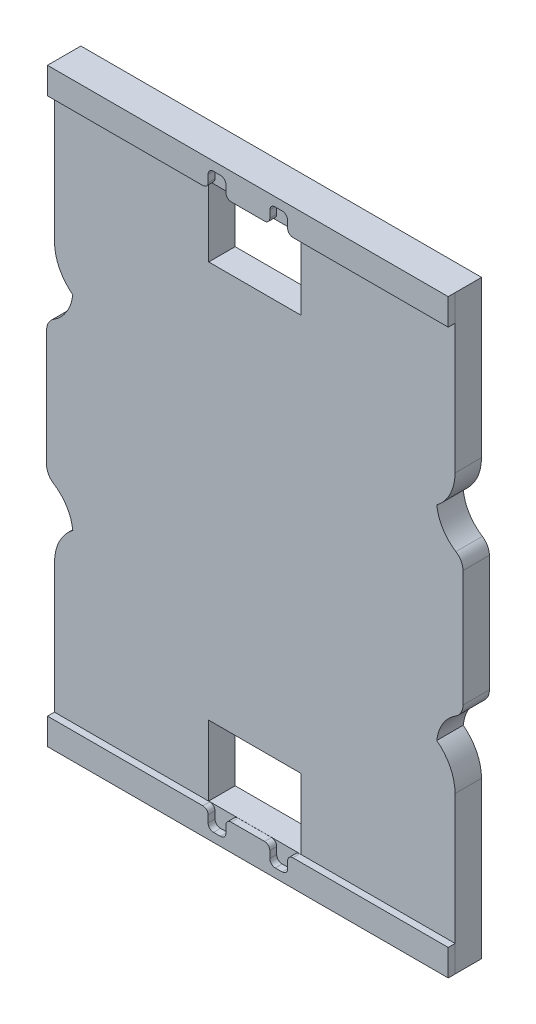
from build123d import *

# Parameters (mm, degrees)
BOSS_EXTRUDE1_DEPTH   = 1.57
BOSS_EXTRUDE1_2_DEPTH = 1.57
SKETCH2_W             = 20.9
SKETCH2_H             = 15.9
SKETCH2_W_2           = 94.45
SKETCH2_H_2           = 0.025
SKETCH2_H_3           = 6.025
BOSS_EXTRUDE3_DEPTH   = 6


with BuildPart() as part:
    # Sketch1 → Boss-Extrude1 (new body)
    with BuildSketch(Plane.XY.offset(7.67)):
        with BuildLine():
            Line((-10.2, 60.925), (-45.45, 60.925))
            Line((-45.45, 60.925), (-45.45, 66.925))
            Line((-45.45, 66.925), (45.45, 66.925))
            Line((45.45, 66.925), (45.45, 60.925))
            Line((45.45, 60.925), (10.2, 60.925))
            ThreePointArc((10.2, 60.925), (9.369149532, 61.269149532), (9.025, 62.1))
            Line((9.025, 62.1), (9.025, 63.7))
            ThreePointArc((9.025, 63.7), (8.666205807, 64.566205807), (7.8, 64.925))
            Line((7.8, 64.925), (6.2, 64.925))
            ThreePointArc((6.2, 64.925), (5.333794193, 64.566205807), (4.975, 63.7))
            Line((4.975, 63.7), (4.975, 62.1))
            ThreePointArc((4.975, 62.1), (4.630850468, 61.269149532), (3.8, 60.925))
            Line((3.8, 60.925), (-3.8, 60.925))
            ThreePointArc((-3.8, 60.925), (-4.630850468, 61.269149532), (-4.975, 62.1))
            Line((-4.975, 62.1), (-4.975, 63.7))
            ThreePointArc((-4.975, 63.7), (-5.333794193, 64.566205807), (-6.2, 64.925))
            Line((-6.2, 64.925), (-7.8, 64.925))
            ThreePointArc((-7.8, 64.925), (-8.666205807, 64.566205807), (-9.025, 63.7))
            Line((-9.025, 63.7), (-9.025, 62.1))
            ThreePointArc((-9.025, 62.1), (-9.369149532, 61.269149532), (-10.2, 60.925))
        make_face()
    extrude(amount=-BOSS_EXTRUDE1_DEPTH)



with BuildPart() as body_2:
    # Sketch1 → Boss-Extrude1 2 (new body)
    with BuildSketch(Plane.XY.offset(7.67)):
        with BuildLine():
            Line((10.2, -60.925), (45.45, -60.925))
            Line((45.45, -60.925), (45.45, -66.925))
            Line((45.45, -66.925), (-45.45, -66.925))
            Line((-45.45, -66.925), (-45.45, -60.925))
            Line((-45.45, -60.925), (-10.2, -60.925))
            ThreePointArc((-10.2, -60.925), (-9.369149532, -61.269149532), (-9.025, -62.1))
            Line((-9.025, -62.1), (-9.025, -63.7))
            ThreePointArc((-9.025, -63.7), (-8.666205807, -64.566205807), (-7.8, -64.925))
            Line((-7.8, -64.925), (-6.2, -64.925))
            ThreePointArc((-6.2, -64.925), (-5.333794193, -64.566205807), (-4.975, -63.7))
            Line((-4.975, -63.7), (-4.975, -62.1))
            ThreePointArc((-4.975, -62.1), (-4.630850468, -61.269149532), (-3.8, -60.925))
            Line((-3.8, -60.925), (3.8, -60.925))
            ThreePointArc((3.8, -60.925), (4.630850468, -61.269149532), (4.975, -62.1))
            Line((4.975, -62.1), (4.975, -63.7))
            ThreePointArc((4.975, -63.7), (5.333794193, -64.566205807), (6.2, -64.925))
            Line((6.2, -64.925), (7.8, -64.925))
            ThreePointArc((7.8, -64.925), (8.666205807, -64.566205807), (9.025, -63.7))
            Line((9.025, -63.7), (9.025, -62.1))
            ThreePointArc((9.025, -62.1), (9.369149532, -61.269149532), (10.2, -60.925))
        make_face()
    extrude(amount=-BOSS_EXTRUDE1_2_DEPTH)


with BuildPart() as part_1:
    add(part.part)

    add(body_2.part)  # Boss-Extrude3 merges body 2
    # Sketch2 → Boss-Extrude3 (add)
    with BuildSketch(Plane.XY.offset(0.1)):
        with BuildLine():
            ThreePointArc((-45.621153846, 16.138909297), (-42.65479168, 19.145865857), (-41.280343138, 23.139859279))
            ThreePointArc((-41.280343138, 23.139859279), (-44.331790058, 26.826513587), (-45.425, 31.485659466))
            Line((-45.425, 31.485659466), (-45.45, 66.925))
            Line((-45.45, 66.925), (45.45, 66.925))
            Line((45.45, 66.925), (45.425, 31.485659466))
            ThreePointArc((45.425, 31.485659466), (44.331790058, 26.826513587), (41.280343138, 23.139859279))
            ThreePointArc((41.280343138, 23.139859279), (42.65479168, 19.145865857), (45.621153846, 16.138909297))
            ThreePointArc((45.621153846, 16.138909297), (46.797776617, 14.880036243), (47.225, 13.21070024))
            Line((47.225, 13.21070024), (47.225, 0.025))
            Line((47.225, 0.025), (-47.225, 0.025))
            Line((-47.225, 0.025), (-47.225, 13.21070024))
            ThreePointArc((-47.225, 13.21070024), (-46.797776617, 14.880036243), (-45.621153846, 16.138909297))
        make_face()
        with Locations((0, 52.95)):
            Rectangle(SKETCH2_W, SKETCH2_H, mode=Mode.SUBTRACT)
        with Locations((0, 0.0125)):
            Rectangle(SKETCH2_W_2, SKETCH2_H_2)
        with Locations((0, -0.0125)):
            Rectangle(SKETCH2_W_2, SKETCH2_H_2)
        with BuildLine():
            Line((-47.225, -0.025), (-47.225, -13.21070024))
            ThreePointArc((-47.225, -13.21070024), (-46.797776617, -14.880036243), (-45.621153846, -16.138909297))
            ThreePointArc((-45.621153846, -16.138909297), (-42.65479168, -19.145865857), (-41.280343138, -23.139859279))
            ThreePointArc((-41.280343138, -23.139859279), (-44.331790058, -26.826513587), (-45.425, -31.485659466))
            Line((-45.425, -31.485659466), (-45.45, -66.925))
            Line((-45.45, -66.925), (-30.45, -66.925))
            Line((-30.45, -66.925), (-30.45, -45))
            Line((-30.45, -45), (-10.45, -45))
            Line((-10.45, -45), (10.45, -45))
            Line((10.45, -45), (30.45, -45))
            Line((30.45, -45), (30.45, -66.925))
            Line((30.45, -66.925), (45.45, -66.925))
            Line((45.45, -66.925), (45.425, -31.485659466))
            ThreePointArc((45.425, -31.485659466), (44.331790058, -26.826513587), (41.280343138, -23.139859279))
            ThreePointArc((41.280343138, -23.139859279), (42.65479168, -19.145865857), (45.621153846, -16.138909297))
            ThreePointArc((45.621153846, -16.138909297), (46.797776617, -14.880036243), (47.225, -13.21070024))
            Line((47.225, -13.21070024), (47.225, -0.025))
            Line((47.225, -0.025), (-47.225, -0.025))
        make_face()
        Polygon((10.45, -60.9), (10.45, -66.925), (30.45, -66.925), (30.45, -45), (10.45, -45), align=None)
        Polygon((-30.45, -45), (-30.45, -66.925), (-10.45, -66.925), (-10.45, -60.9), (-10.45, -45), align=None)
        with Locations((0, -63.9125)):
            Rectangle(SKETCH2_W, SKETCH2_H_3)
    extrude(amount=BOSS_EXTRUDE3_DEPTH)


solid = part_1.part
